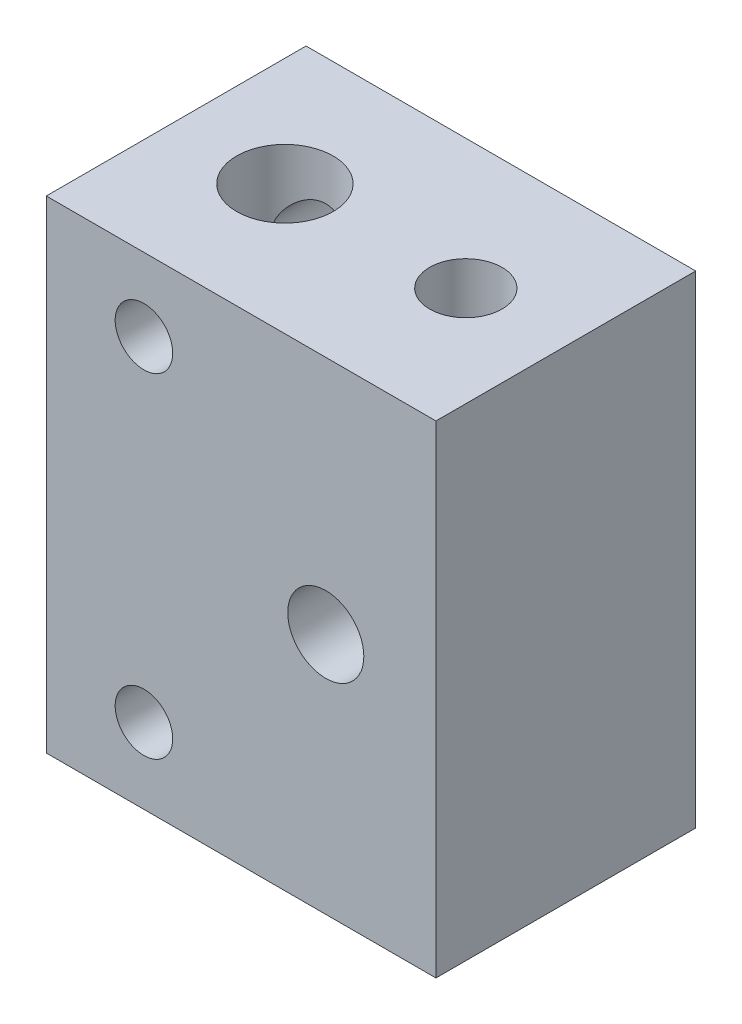
from build123d import *

# Parameters (mm, degrees)
SKETCH1_W           = 21
SKETCH1_H           = 14
BOSS_EXTRUDE2_DEPTH = 26
CUT_EXTRUDE1_DEPTH  = 26
CUT_EXTRUDE2_DEPTH  = 26


with BuildPart() as part:
    # Sketch1 → Boss-Extrude2 (new body)
    with BuildSketch(Plane(origin=(0, 0, 0), x_dir=(1, 0, 0), z_dir=(0, 1, 0))):
        Rectangle(SKETCH1_W, SKETCH1_H)
    extrude(amount=BOSS_EXTRUDE2_DEPTH)

    # Sketch3 → Cut-Extrude1 (cut)
    with BuildSketch(Plane.XY.offset(7)):
        with BuildLine():
            ThreePointArc((-3.687132732, 4.065349549), (-5.237132732, 5.615349549), (-6.787132732, 4.065349549))
            ThreePointArc((-6.787132732, 4.065349549), (-5.237132732, 2.515349549), (-3.687132732, 4.065349549))
        make_face()
        with BuildLine():
            ThreePointArc((6.612867268, 13.065349549), (4.562867268, 15.115349549), (2.512867268, 13.065349549))
            ThreePointArc((2.512867268, 13.065349549), (4.562867268, 11.015349549), (6.612867268, 13.065349549))
        make_face()
        with BuildLine():
            ThreePointArc((-3.687132732, 22.065349549), (-5.237132732, 23.615349549), (-6.787132732, 22.065349549))
            ThreePointArc((-6.787132732, 22.065349549), (-5.237132732, 20.515349549), (-3.687132732, 22.065349549))
        make_face()
    extrude(amount=-CUT_EXTRUDE1_DEPTH, mode=Mode.SUBTRACT)

    # Sketch4 → Cut-Extrude2 (cut)
    with BuildSketch(Plane(origin=(0, 26, 0), x_dir=(1, 0, 0), z_dir=(0, 1, 0))):
        with BuildLine():
            ThreePointArc((-2.040636321, 0), (-4.640636321, 2.6), (-7.240636321, 0))
            ThreePointArc((-7.240636321, 0), (-4.640636321, -2.6), (-2.040636321, 0))
        make_face()
        with BuildLine():
            ThreePointArc((3.159363679, 0), (5.109363679, -1.95), (7.059363679, 0))
            ThreePointArc((7.059363679, 0), (5.109363679, 1.95), (3.159363679, 0))
        make_face()
    extrude(amount=-CUT_EXTRUDE2_DEPTH, mode=Mode.SUBTRACT)


solid = part.part
